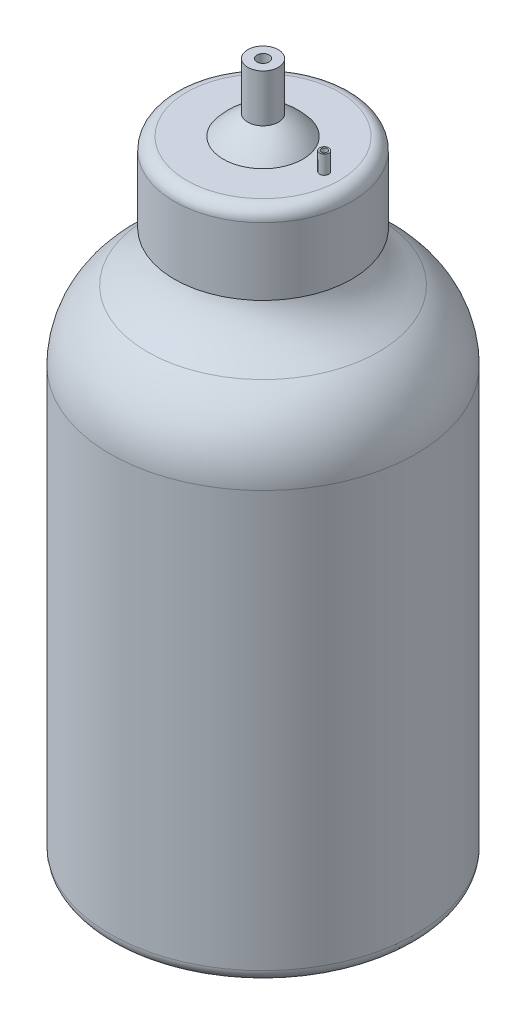
from build123d import *

# Parameters (mm, degrees)
FILLET1_R           = 2
SHELL1_T            = -1
SKETCH3_R           = 12
SKETCH3_R_2         = 11
EXTRUDE_THIN1_DEPTH = 10
FILLET2_R           = 2
SKETCH5_R           = 0.5
CUT_EXTRUDE1_DEPTH  = 10
SKETCH5_3_R         = 0.75
SKETCH5_3_R_2       = 0.5
BOSS_EXTRUDE1_DEPTH = 3


with BuildPart() as part:
    # Sketch1 → Revolve1 (revolve)
    with BuildSketch(Plane.XY):
        with BuildLine():
            Line((0, 0), (25, 0))
            Line((25, 0), (25, 70))
            ThreePointArc((25, 70), (23.380232642, 76.466921689), (18.903400873, 81.406830568))
            add(Edge.make_bspline(
                [(12, 90), (12, 88.183937424), (13.885995591, 84.458788638), (17.431185098, 82.390672764), (18.903400873, 81.406830568)],
                knots=[0, 0, 0, 0, 0.32248294, 0.670614434, 0.670614434, 0.670614434, 0.670614434], degree=3))
            Line((12, 90), (0, 90))
            Line((0, 90), (0, 0))
        make_face()
    revolve(axis=Axis((0, 0, 0), (0, 1, 0)))

    # Fillet1
    fillet1_edges = [part.edges().sort_by_distance(p)[0] for p in [
        (-25, 0, 0),
    ]]
    fillet(fillet1_edges, radius=FILLET1_R)

    # Shell1
    shell1_openings = [part.faces().sort_by_distance(p)[0] for p in [
        (0, 90, 0),
    ]]
    offset(amount=SHELL1_T, openings=shell1_openings, kind=Kind.INTERSECTION)

    # Sketch3 → Extrude-Thin1 (add)
    with BuildSketch(Plane(origin=(0, 90, 0), x_dir=(1, 0, 0), z_dir=(0, 1, 0))):
        Circle(SKETCH3_R)
        Circle(SKETCH3_R_2, mode=Mode.SUBTRACT)
    extrude(amount=EXTRUDE_THIN1_DEPTH)


with BuildPart() as body_2:
    # Sketch4 → Revolve2 (revolve)
    with BuildSketch(Plane.XY):
        with BuildLine():
            Line((-13, 89.5), (-13, 101))
            Line((-13, 101), (-2.5, 101))
            Line((-2.5, 101), (-2.5, 11))
            Line((-2.5, 11), (-1, 11))
            Line((-1, 11), (-1, 101))
            Line((-1, 101), (-1, 113.521479729))
            Line((-1, 113.521479729), (-2.5, 113.521479729))
            Line((-2.5, 113.521479729), (-2.5, 105.743021739))
            add(Edge.make_bspline(
                [(-6.5, 102.5), (-4.835037084, 104.54169867), (-2.5, 105.743021739)],
                knots=[0, 0, 0, 1, 1, 1], degree=2))
            Line((-6.5, 102.5), (-14.5, 102.5))
            Line((-14.5, 102.5), (-14.5, 89.5))
            Line((-14.5, 89.5), (-13, 89.5))
        make_face()
    revolve(axis=Axis((0, 100, 0), (0, 1, 0)))

    # Fillet2
    fillet2_edges = [body_2.edges().sort_by_distance(p)[0] for p in [
        (14.5, 102.5, 0),
    ]]
    fillet(fillet2_edges, radius=FILLET2_R)

    # Sketch5 → Cut-Extrude1 (cut)
    with BuildSketch(Plane(origin=(0, 102.5, 0), x_dir=(1, 0, 0), z_dir=(0, 1, 0))):
        with Locations((10, 0)):
            Circle(SKETCH5_R)
    extrude(amount=-CUT_EXTRUDE1_DEPTH, mode=Mode.SUBTRACT)

    # Sketch5_3 → Boss-Extrude1 (add)
    with BuildSketch(Plane(origin=(0, 102.5, 0), x_dir=(1, 0, 0), z_dir=(0, 1, 0))):
        with Locations((10, 0)):
            Circle(SKETCH5_3_R)
        with Locations((10, 0)):
            Circle(SKETCH5_3_R_2, mode=Mode.SUBTRACT)
    extrude(amount=BOSS_EXTRUDE1_DEPTH)


solid = Compound([part.part, body_2.part])
